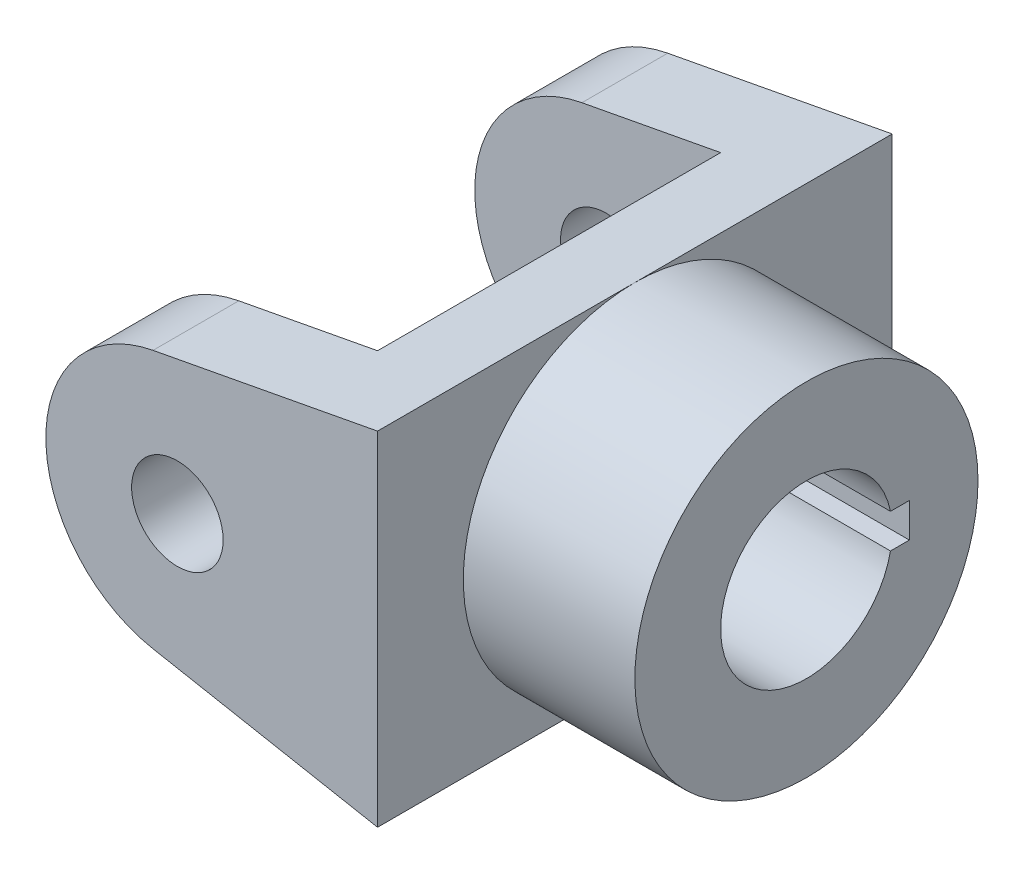
from build123d import *

# Parameters (mm, degrees)
SKETCH1_W           = 88
SKETCH1_H           = 90
BOSS_EXTRUDE1_DEPTH = 60
SKETCH2_W           = 43
SKETCH2_H           = 60
SKETCH2_W_2         = 30
SKETCH2_H_2         = 90
CUT_EXTRUDE1_DEPTH  = 60
SKETCH3_R           = 8
CUT_EXTRUDE2_DEPTH  = 125
CUT_EXTRUDE3_DEPTH  = 30
BOSS_EXTRUDE2_START = 30
SKETCH4_4_R         = 30
BOSS_EXTRUDE2_DEPTH = 30


with BuildPart() as part:
    # Sketch1 → Boss-Extrude1 (new body)
    with BuildSketch(Plane(origin=(0, 0, 0), x_dir=(1, 0, 0), z_dir=(0, 1, 0))):
        Rectangle(SKETCH1_W, SKETCH1_H)
    extrude(amount=BOSS_EXTRUDE1_DEPTH)

    # Sketch2 → Cut-Extrude1 (cut)
    with BuildSketch(Plane(origin=(0, 60, 0), x_dir=(1, 0, 0), z_dir=(0, 1, 0))):
        with Locations((-22.5, 0)):
            Rectangle(SKETCH2_W, SKETCH2_H)
        with Locations((29, 0)):
            Rectangle(SKETCH2_W_2, SKETCH2_H_2)
    extrude(amount=-CUT_EXTRUDE1_DEPTH, mode=Mode.SUBTRACT)

    # Sketch3 → Cut-Extrude2 (cut)
    with BuildSketch(Plane.XY.offset(45)):
        with BuildLine():
            ThreePointArc((-44, 30), (-38.705339862, 44.68063147), (-25.259048664, 52.602223441))
            Line((-25.259048664, 52.602223441), (14, 60))
            Line((14, 60), (-44, 60))
            Line((-44, 60), (-44, 30))
        make_face()
        with BuildLine():
            ThreePointArc((-25.259048664, 7.397776559), (-38.705339862, 15.31936853), (-44, 30))
            Line((-44, 30), (-44, 0))
            Line((-44, 0), (14, 0))
            Line((14, 0), (-25.259048664, 7.397776559))
        make_face()
        with Locations((-21, 30)):
            Circle(SKETCH3_R)
    extrude(amount=-CUT_EXTRUDE2_DEPTH, mode=Mode.SUBTRACT)

    # Sketch4 → Cut-Extrude3 (cut)
    with BuildSketch(Plane(origin=(14, 0, 0), x_dir=(0, 0, -1), z_dir=(1, 0, 0))):
        with BuildLine():
            Line((18, 33), (14.696938457, 33))
            ThreePointArc((14.696938457, 33), (-15, 30), (14.696938457, 27))
            Line((14.696938457, 27), (18, 27))
            Line((18, 27), (18, 33))
        make_face()
    extrude(amount=-CUT_EXTRUDE3_DEPTH, mode=Mode.SUBTRACT)

    # Sketch4_4 → Boss-Extrude2 (add)
    with BuildSketch(Plane(origin=(14, 0, 0), x_dir=(0, 0, -1), z_dir=(1, 0, 0)).offset(BOSS_EXTRUDE2_START)):
        with Locations((0, 30)):
            Circle(SKETCH4_4_R)
        with BuildLine():
            Line((14.696938457, 33), (18, 33))
            Line((18, 33), (18, 27))
            Line((18, 27), (14.696938457, 27))
            ThreePointArc((14.696938457, 27), (-15, 30), (14.696938457, 33))
        make_face(mode=Mode.SUBTRACT)
    extrude(amount=-BOSS_EXTRUDE2_DEPTH)


solid = part.part
